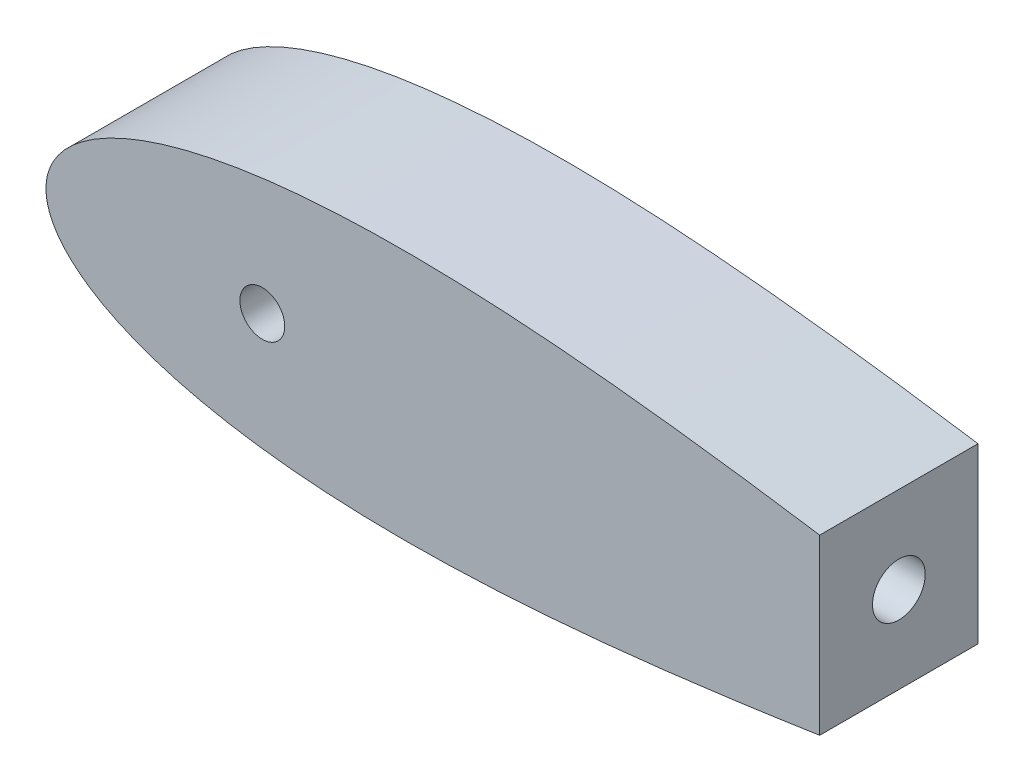
from build123d import *

# Parameters (mm, degrees)
BOSS_EXTRUDE1_DEPTH     = 76.2
SKETCH3_R               = 10.795
CUT_EXTRUDE2_DEPTH      = 76.2
SKETCH6_R               = 6.35
CUT_EXTRUDE3_DEPTH      = 53.34
CUT_EXTRUDE3_DEPTH_BACK = 0.000254
SKETCH7_R               = 1.5875
CUT_EXTRUDE4_DEPTH      = 30.48
SKETCH8_W               = 304.8
SKETCH8_H               = 127
CUT_EXTRUDE5_DEPTH      = 76.2
SKETCH9_R               = 12.7
CUT_EXTRUDE6_DEPTH      = 101.6
SKETCH10_R              = 3.175
CUT_EXTRUDE7_DEPTH      = 57.15


with BuildPart() as part:
    # Sketch1 → Boss-Extrude1 (new body)
    with BuildSketch(Plane.XY):
        with BuildLine():
            Line((643.966787522, 0), (643.599082689, 0))
            Line((643.599082689, 0), (643.599082689, -1.016))
            ThreePointArc((643.599082689, -1.016), (643.872033494, -0.540245973), (643.966787522, 0))
        make_face()
        with BuildLine():
            Line((643.599082689, -1.016), (643.599082689, 0))
            Line((643.599082689, 0), (641.567082689, 0))
            ThreePointArc((641.567082689, 0), (642.269121423, -1.135922533), (643.599082689, -1.016))
        make_face()
        with BuildLine():
            Line((641.567082689, 0), (643.599082689, 0))
            Line((643.599082689, 0), (643.966787522, 0))
            ThreePointArc((643.966787522, 0), (643.547407924, 1.075012082), (642.510849283, 1.582039112))
            add(Edge.make_bspline(
                [(642.510849283, 1.582039112), (641.993392355, 1.625070631), (638.093728429, 1.953546407), (630.413817462, 2.663385493), (619.014124193, 3.849253664), (606.374988512, 5.304428983), (592.543922516, 7.037634907), (577.585454095, 9.050636147), (561.564270734, 11.338919625), (544.549749946, 13.890665375), (526.614143658, 16.687720753), (507.832591566, 19.705111663), (488.282710288, 22.911672601), (468.044367735, 26.27043606), (447.199424328, 29.739007432), (425.831595832, 33.270324121), (404.02631566, 36.813220545), (381.870662856, 40.313266856), (359.453314895, 43.713502532), (336.86454415, 46.955447457), (314.196207315, 49.979843895), (291.541767704, 52.727712704), (268.996310773, 55.141201012), (246.65655865, 57.164603829), (224.620860897, 58.745176641), (202.989192599, 59.8341217), (181.863132616, 60.387506142), (161.345829027, 60.366961324), (141.542033828, 59.739895824), (122.558104573, 58.481758104), (104.502313427, 56.574303932), (87.485018636, 54.008935199), (71.619696083, 50.784752003), (57.023709725, 46.912543066), (43.82045433, 42.41500246), (32.141645239, 37.332204029), (22.129107375, 31.731455339), (13.932423524, 25.726412106), (7.689616489, 19.513207632), (3.463136343, 13.420354421), (1.106333228, 7.923389435), (0.154611582, 3.513796615), (0, 1.007496172), (0, 0)],
                knots=[0.020157042, 0.020157042, 0.020157042, 0.020157042, 0.021270888, 0.028552555, 0.036780684, 0.045920102, 0.055931764, 0.066772884, 0.07839713, 0.090754827, 0.103793165, 0.117456432, 0.131686226, 0.146421738, 0.161599998, 0.177156133, 0.193023668, 0.209134786, 0.225420633, 0.241811602, 0.258237647, 0.274628557, 0.290914287, 0.307025229, 0.322892517, 0.338448342, 0.353626207, 0.368361232, 0.382590428, 0.396252961, 0.409290412, 0.42164701, 0.433269881, 0.444109249, 0.45411864, 0.463255055, 0.471479114, 0.478755289, 0.485052318, 0.490344026, 0.494609833, 0.497833231, 0.5, 0.5, 0.5, 0.5], degree=3))
            Line((0, 0), (27.94, 0))
            ThreePointArc((27.94, 0), (40.64, 12.7), (53.34, 0))
            Line((53.34, 0), (93.345, 0))
            ThreePointArc((93.345, 0), (104.14, 10.795), (114.935, 0))
            Line((114.935, 0), (460.660965279, 0))
            Line((460.660965279, 0), (473.360965279, 0))
            Line((473.360965279, 0), (641.567082689, 0))
        make_face()
        with BuildLine():
            ThreePointArc((642.510849283, -1.582039112), (643.111845681, -1.408373102), (643.599082689, -1.016))
            ThreePointArc((643.599082689, -1.016), (642.269121423, -1.135922533), (641.567082689, 0))
            Line((641.567082689, 0), (473.360965279, 0))
            Line((473.360965279, 0), (460.660965279, 0))
            Line((460.660965279, 0), (114.935, 0))
            ThreePointArc((114.935, 0), (104.14, -10.795), (93.345, 0))
            Line((93.345, 0), (53.34, 0))
            ThreePointArc((53.34, 0), (40.64, -12.7), (27.94, 0))
            Line((27.94, 0), (0, 0))
            add(Edge.make_bspline(
                [(0, 0), (0, -1.007496172), (0.154611582, -3.513796615), (1.106333228, -7.923389435), (3.463136343, -13.420354421), (7.689616489, -19.513207632), (13.932423524, -25.726412106), (22.129107375, -31.731455339), (32.141645239, -37.332204029), (43.82045433, -42.41500246), (57.023709725, -46.912543066), (71.619696083, -50.784752003), (87.485018636, -54.008935199), (104.502313427, -56.574303932), (122.558104573, -58.481758104), (141.542033828, -59.739895824), (161.345829027, -60.366961324), (181.863132616, -60.387506142), (202.989192599, -59.8341217), (224.620860897, -58.745176641), (246.65655865, -57.164603829), (268.996310773, -55.141201012), (291.541767704, -52.727712704), (314.196207315, -49.979843895), (336.86454415, -46.955447457), (359.453314895, -43.713502532), (381.870662856, -40.313266856), (404.02631566, -36.813220545), (425.831595832, -33.270324121), (447.199424328, -29.739007432), (468.044367735, -26.27043606), (488.282710288, -22.911672601), (507.832591566, -19.705111663), (526.614143658, -16.687720753), (544.549749946, -13.890665375), (561.564270734, -11.338919625), (577.585454095, -9.050636147), (592.543922516, -7.037634907), (606.374988512, -5.304428983), (619.014124193, -3.849253664), (630.413817462, -2.663385493), (638.093728429, -1.953546407), (641.993392355, -1.625070631), (642.510849283, -1.582039112)],
                knots=[0.5, 0.5, 0.5, 0.5, 0.502166769, 0.505390167, 0.509655974, 0.514947682, 0.521244711, 0.528520886, 0.536744945, 0.54588136, 0.555890751, 0.566730119, 0.57835299, 0.590709588, 0.603747039, 0.617409572, 0.631638768, 0.646373793, 0.661551658, 0.677107483, 0.692974771, 0.709085713, 0.725371443, 0.741762353, 0.758188398, 0.774579367, 0.790865214, 0.806976332, 0.822843867, 0.838400002, 0.853578262, 0.868313774, 0.882543568, 0.896206835, 0.909245173, 0.92160287, 0.933227116, 0.944068236, 0.954079898, 0.963219316, 0.971447445, 0.978729112, 0.979842958, 0.979842958, 0.979842958, 0.979842958], degree=3))
        make_face()
        with BuildLine():
            ThreePointArc((643.966787522, 0), (643.872033494, -0.540245973), (643.599082689, -1.016))
            ThreePointArc((643.599082689, -1.016), (643.111845681, -1.408373102), (642.510849283, -1.582039112))
            add(Edge.make_bspline(
                [(642.510849283, -1.582039112), (644.922074617, -1.381522545), (649.798936594, -1.000308437), (656.504964311, -0.543558383), (662.850933168, -0.234427605), (666.344759683, -0.054696708), (670.56, -0.015678595), (670.56, 0)],
                knots=[0.979842958, 0.979842958, 0.979842958, 0.979842958, 0.985033212, 0.990332793, 0.994605218, 0.997832222, 1, 1, 1, 1], degree=3))
            add(Edge.make_bspline(
                [(670.56, 0), (670.56, 0.015678595), (666.344759683, 0.054696708), (662.850933168, 0.234427605), (656.504964311, 0.543558383), (649.798936594, 1.000308437), (644.922074617, 1.381522545), (642.510849283, 1.582039112)],
                knots=[0, 0, 0, 0, 0.002167778, 0.005394782, 0.009667207, 0.014966788, 0.020157042, 0.020157042, 0.020157042, 0.020157042], degree=3))
            ThreePointArc((642.510849283, 1.582039112), (643.547407924, 1.075012082), (643.966787522, 0))
        make_face()
        with BuildLine():
            ThreePointArc((53.34, 0), (40.64, 12.7), (27.94, 0))
            Line((27.94, 0), (53.34, 0))
        make_face()
        with BuildLine():
            Line((53.34, 0), (27.94, 0))
            ThreePointArc((27.94, 0), (40.64, -12.7), (53.34, 0))
        make_face()
        with BuildLine():
            ThreePointArc((93.345, 0), (104.14, -10.795), (114.935, 0))
            Line((114.935, 0), (93.345, 0))
        make_face()
        with BuildLine():
            Line((93.345, 0), (114.935, 0))
            ThreePointArc((114.935, 0), (104.14, 10.795), (93.345, 0))
        make_face()
    extrude(amount=BOSS_EXTRUDE1_DEPTH)

    # Sketch3 → Cut-Extrude2 (cut)
    with BuildSketch(Plane.XY.offset(76.2)):
        with Locations((104.139232412, 0)):
            Circle(SKETCH3_R)
    extrude(amount=-CUT_EXTRUDE2_DEPTH, mode=Mode.SUBTRACT)

    # Sketch6 → Cut-Extrude3 (cut, two sides)
    with BuildSketch(Plane(origin=(0, 0, 0), x_dir=(0, 0, -1), z_dir=(1, 0, 0))) as cut_extrude3_sk:
        with Locations((-20.32, 0)):
            Circle(SKETCH6_R)
    extrude(amount=CUT_EXTRUDE3_DEPTH, mode=Mode.SUBTRACT)
    extrude(cut_extrude3_sk.sketch, amount=-CUT_EXTRUDE3_DEPTH_BACK, mode=Mode.SUBTRACT)

    # Sketch7 → Cut-Extrude4 (cut)
    with BuildSketch(Plane(origin=(0, 0, 0), x_dir=(-1, 0, 0), z_dir=(0, 0, -1))):
        with Locations((-38.1, 0)):
            Circle(SKETCH7_R)
        with Locations((-50.8, 0)):
            Circle(SKETCH7_R)
    extrude(amount=-CUT_EXTRUDE4_DEPTH, mode=Mode.SUBTRACT)

    # Sketch8 → Cut-Extrude5 (cut)
    with BuildSketch(Plane(origin=(0, 0, 0), x_dir=(-1, 0, 0), z_dir=(0, 0, -1))):
        with Locations((-524.843319628, 0.490119432)):
            Rectangle(SKETCH8_W, SKETCH8_H)
    extrude(amount=-CUT_EXTRUDE5_DEPTH, mode=Mode.SUBTRACT)

    # Sketch9 → Cut-Extrude6 (cut)
    with BuildSketch(Plane(origin=(372.443319628, 0, 0), x_dir=(0, 0, -1), z_dir=(1, 0, 0))):
        with Locations((-38.1, 0)):
            Circle(SKETCH9_R)
    extrude(amount=-CUT_EXTRUDE6_DEPTH, mode=Mode.SUBTRACT)

    # Sketch10 → Cut-Extrude7 (cut)
    with BuildSketch(Plane(origin=(0, 0, 0), x_dir=(-1, 0, 0), z_dir=(0, 0, -1))):
        with Locations((-343.868319647, 0)):
            Circle(SKETCH10_R)
        with Locations((-286.718319647, 0)):
            Circle(SKETCH10_R)
    extrude(amount=-CUT_EXTRUDE7_DEPTH, mode=Mode.SUBTRACT)


solid = part.part
